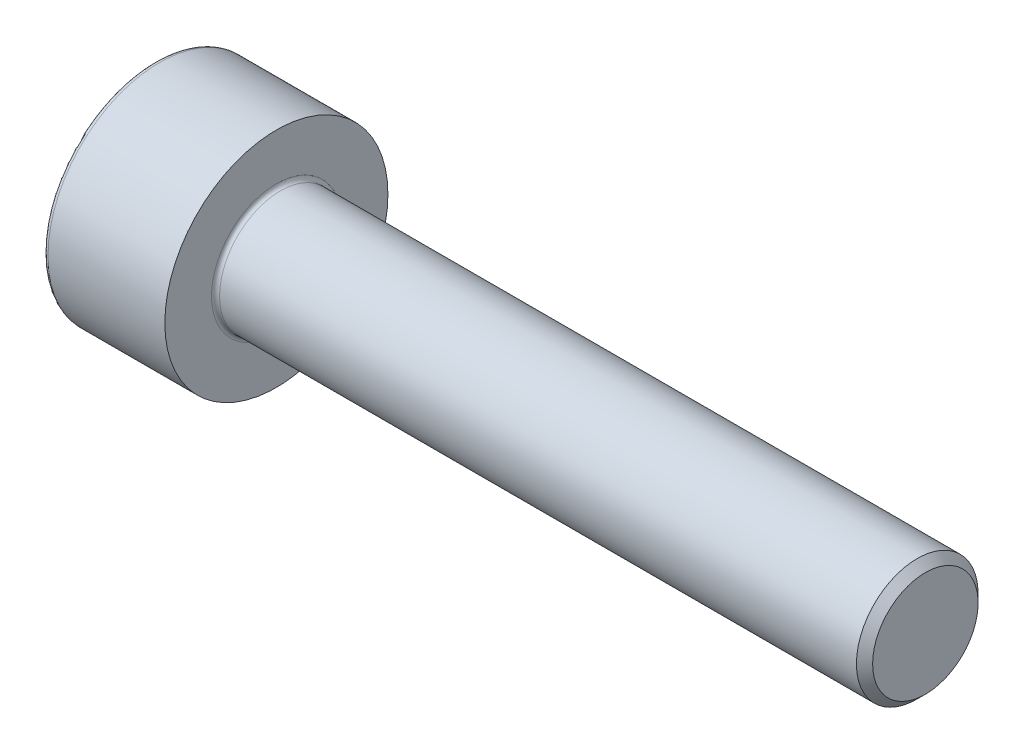
from build123d import *

# Parameters (mm, degrees)
FILLET1_R      = 0.1
FILLET2_R      = 0.12
CHAMFER1_SIZE  = 0.2
EXTRUDE1_DEPTH = 1.3


with BuildPart() as part:
    # Sketch1 → Revolve1 (revolve)
    with BuildSketch(Plane.XY, mode=Mode.PRIVATE) as revolve1_sk:
        Polygon((3, 1.5), (3, 0), (4.279914881, 0), (19, 0), (19, 1.5), align=None)
        Polygon((0, 2.75), (0, 0), (3, 0), (3, 1.5), (3, 2.75), align=None)
    revolve(revolve1_sk.sketch.rotate(Axis((0, 0, 0), (1, 0, 0)), 90), axis=Axis((0, 0, 0), (1, 0, 0)))

    # Fillet1
    fillet1_edges = [part.edges().sort_by_distance(p)[0] for p in [
        (3, 0, -1.5),
    ]]
    fillet(fillet1_edges, radius=FILLET1_R)

    # Fillet2
    fillet2_edges = [part.edges().sort_by_distance(p)[0] for p in [
        (0, 0, -2.75),
    ]]
    fillet(fillet2_edges, radius=FILLET2_R)

    # Chamfer1
    chamfer1_edges = [part.edges().sort_by_distance(p)[0] for p in [
        (19, 0, -1.5),
    ]]
    chamfer(chamfer1_edges, length=CHAMFER1_SIZE)

    # Sketch2 → Extrude1 (cut)
    with BuildSketch(Plane.ZY):
        Polygon((0, 1.443375673), (-1.25, 0.721687836), (-1.25, -0.721687836), (0, -1.443375673), (1.25, -0.721687836), (1.25, 0.721687836), align=None)
    extrude(amount=-EXTRUDE1_DEPTH, mode=Mode.SUBTRACT)


solid = part.part
